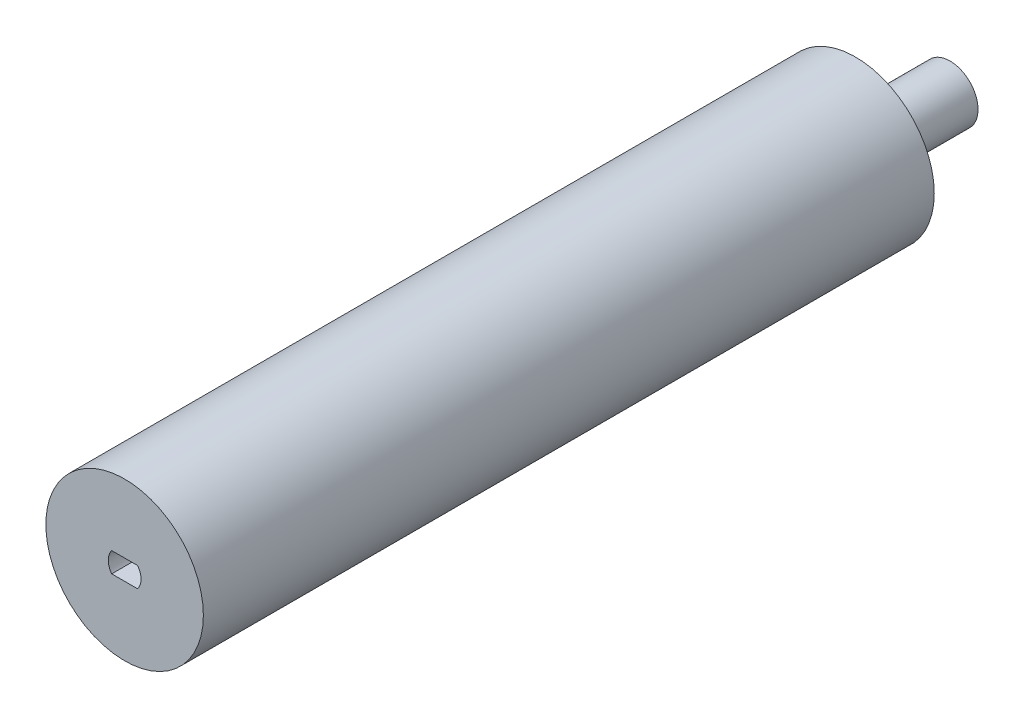
from build123d import *

# Parameters (mm, degrees)
SKETCH2_R           = 12.5
BOSS_EXTRUDE1_DEPTH = 116
SKETCH3_R           = 4.45
BOSS_EXTRUDE2_DEPTH = 15
CUT_EXTRUDE1_DEPTH  = 10


with BuildPart() as part:
    # Sketch2 → Boss-Extrude1 (new body)
    with BuildSketch(Plane.XY):
        Circle(SKETCH2_R)
    extrude(amount=-BOSS_EXTRUDE1_DEPTH)

    # Sketch3 → Boss-Extrude2 (add)
    with BuildSketch(Plane(origin=(0, 0, -116), x_dir=(-1, 0, 0), z_dir=(0, 0, -1))):
        Circle(SKETCH3_R)
    extrude(amount=BOSS_EXTRUDE2_DEPTH)

    # Sketch1 → Cut-Extrude1 (cut)
    with BuildSketch(Plane.XY):
        with BuildLine():
            Line((2.051104302, -1.567413373), (-2.047676004, -1.567413373))
            ThreePointArc((-2.047676004, -1.567413373), (-2.598285851, 0.032586627), (-2.047676004, 1.632586627))
            Line((-2.047676004, 1.632586627), (2.051104302, 1.632586627))
            ThreePointArc((2.051104302, 1.632586627), (2.601714149, 0.032586627), (2.051104302, -1.567413373))
        make_face()
    extrude(amount=-CUT_EXTRUDE1_DEPTH, mode=Mode.SUBTRACT)


solid = part.part
